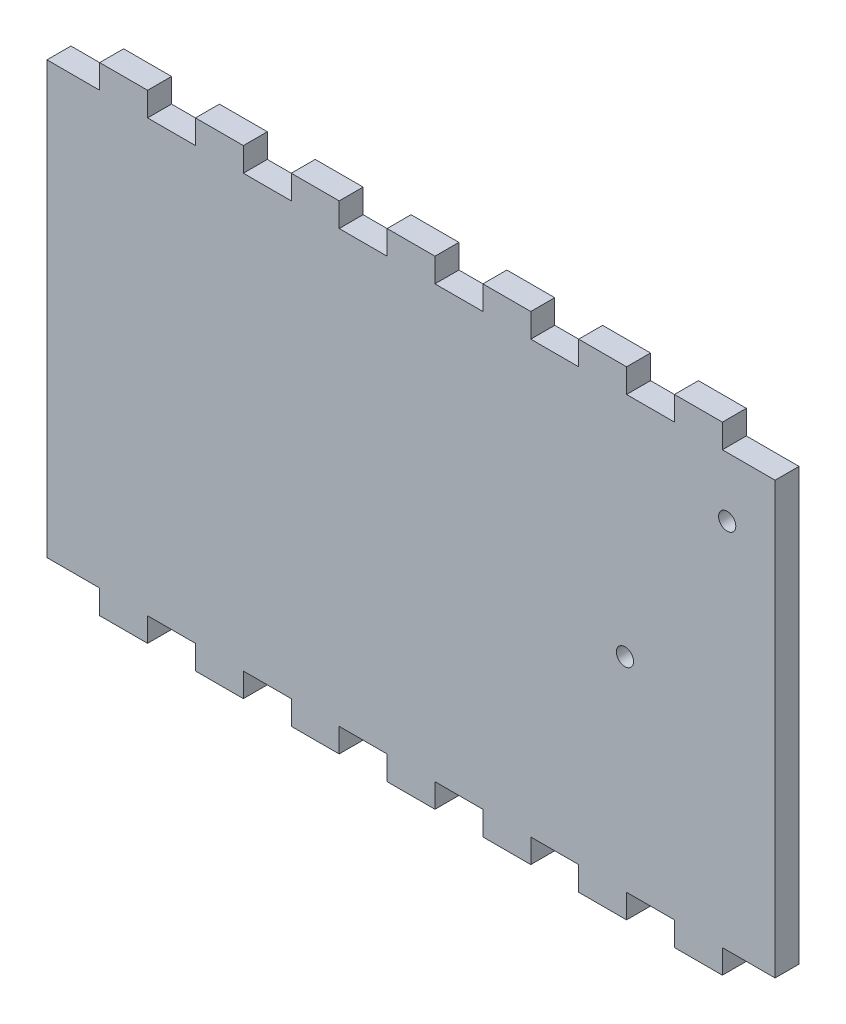
from build123d import *

# Parameters (mm, degrees)
SKETCH1_W           = 96.52
SKETCH1_H           = 63.5
BOSS_EXTRUDE1_DEPTH = 3.175
SKETCH2_W           = 6.985
SKETCH2_H           = 3.175
SKETCH2_W_2         = 6.35
CUT_EXTRUDE1_DEPTH  = 4.175
SKETCH3_R           = 1.143
CUT_EXTRUDE2_DEPTH  = 4.175


with BuildPart() as part:
    # Sketch1 → Boss-Extrude1 (new body)
    with BuildSketch(Plane.XY):
        Rectangle(SKETCH1_W, SKETCH1_H)
    extrude(amount=BOSS_EXTRUDE1_DEPTH)

    # Sketch2 → Cut-Extrude1 (cut, through all)
    with BuildSketch(Plane.XY.offset(3.175)):
        with Locations((-44.7675, -30.1625)):
            Rectangle(SKETCH2_W, SKETCH2_H)
        with Locations((-31.75, -30.1625)):
            Rectangle(SKETCH2_W_2, SKETCH2_H)
        with Locations((-19.05, -30.1625)):
            Rectangle(SKETCH2_W_2, SKETCH2_H)
        with Locations((-6.35, -30.1625)):
            Rectangle(SKETCH2_W_2, SKETCH2_H)
        with Locations((6.35, -30.1625)):
            Rectangle(SKETCH2_W_2, SKETCH2_H)
        with Locations((19.05, -30.1625)):
            Rectangle(SKETCH2_W_2, SKETCH2_H)
        with Locations((31.75, -30.1625)):
            Rectangle(SKETCH2_W_2, SKETCH2_H)
        with Locations((44.7675, -30.1625)):
            Rectangle(SKETCH2_W, SKETCH2_H)
        with Locations((44.7675, 30.1625)):
            Rectangle(SKETCH2_W, SKETCH2_H)
        with Locations((31.75, 30.1625)):
            Rectangle(SKETCH2_W_2, SKETCH2_H)
        with Locations((19.05, 30.1625)):
            Rectangle(SKETCH2_W_2, SKETCH2_H)
        with Locations((6.35, 30.1625)):
            Rectangle(SKETCH2_W_2, SKETCH2_H)
        with Locations((-6.35, 30.1625)):
            Rectangle(SKETCH2_W_2, SKETCH2_H)
        with Locations((-19.05, 30.1625)):
            Rectangle(SKETCH2_W_2, SKETCH2_H)
        with Locations((-31.75, 30.1625)):
            Rectangle(SKETCH2_W_2, SKETCH2_H)
        with Locations((-44.7675, 30.1625)):
            Rectangle(SKETCH2_W, SKETCH2_H)
    extrude(amount=-CUT_EXTRUDE1_DEPTH, mode=Mode.SUBTRACT)

    # Sketch3 → Cut-Extrude2 (cut, through all)
    with BuildSketch(Plane.XY.offset(3.175)):
        with Locations((28.3591, -1.6383)):
            Circle(SKETCH3_R)
        with Locations((41.91, 20.6883)):
            Circle(SKETCH3_R)
    extrude(amount=-CUT_EXTRUDE2_DEPTH, mode=Mode.SUBTRACT)


solid = part.part
